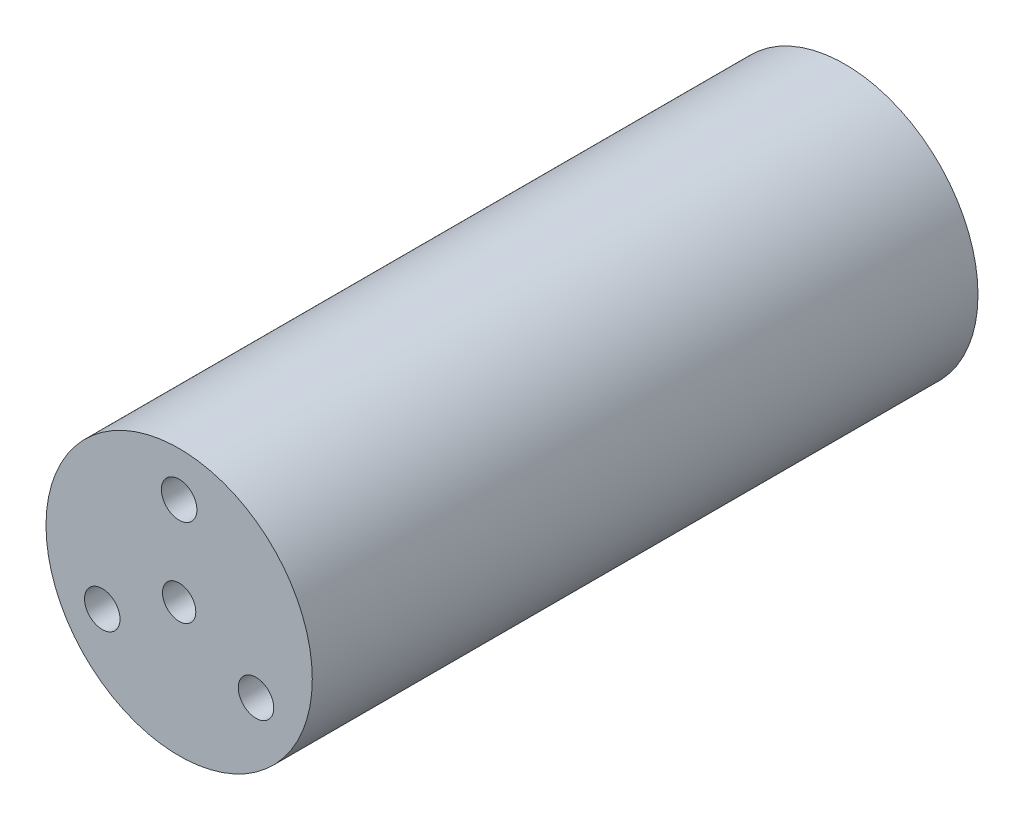
from build123d import *

# Parameters (mm, degrees)
ESQUISSE1_R                  = 6
ESQUISSE1_R_2                = 0.75
EXTRUSION1_DEPTH             = 30
R_P_TITION_CIRCULAIRE1_COUNT = 3
ESQUISSE4_R                  = 1
EXTRUSION2_DEPTH             = 2
R_P_TITION_CIRCULAIRE2_COUNT = 2


with BuildPart() as part:
    # Esquisse1 → Extrusion1 (new body)
    with BuildSketch(Plane.XY):
        Circle(ESQUISSE1_R)
        Circle(ESQUISSE1_R_2, mode=Mode.SUBTRACT)
    extrude(amount=EXTRUSION1_DEPTH)

    # Esquisse2 → Trou taraudé M21 (revolve, cut)
    with BuildSketch(Plane(origin=(0, 4, 30), x_dir=(0, -1, 0), z_dir=(1, 0, 0))):
        Polygon((0, 0), (0, 6.480688495), (0.8, 6), (0.8, 0), align=None)
    trou_taraud_m21 = revolve(axis=Axis((0, 4, 36.35), (0, 0, -1)), mode=Mode.SUBTRACT)

    # Répétition circulaire1: Trou taraudé M21 ×3 about axis
    r_p_tition_circulaire1_axis = Axis((0, 0, 0), (0, 0, 1))
    for i in range(1, R_P_TITION_CIRCULAIRE1_COUNT):
        add(trou_taraud_m21.rotate(r_p_tition_circulaire1_axis, i * 360 / R_P_TITION_CIRCULAIRE1_COUNT), mode=Mode.SUBTRACT)

    # Esquisse4 → Extrusion2 (cut)
    with BuildSketch(Plane(origin=(0, 0, 0), x_dir=(-1, 0, 0), z_dir=(0, 0, -1))):
        with Locations((-1.275535565, -3.791175151)):
            Circle(ESQUISSE4_R)
    extrusion2 = extrude(amount=-EXTRUSION2_DEPTH, mode=Mode.SUBTRACT)

    # Répétition circulaire2: Extrusion2 ×2 about axis
    r_p_tition_circulaire2_axis = Axis((0, 0, 0), (0, 0, 1))
    for i in range(1, R_P_TITION_CIRCULAIRE2_COUNT):
        add(extrusion2.rotate(r_p_tition_circulaire2_axis, i * 360 / R_P_TITION_CIRCULAIRE2_COUNT), mode=Mode.SUBTRACT)


solid = part.part
